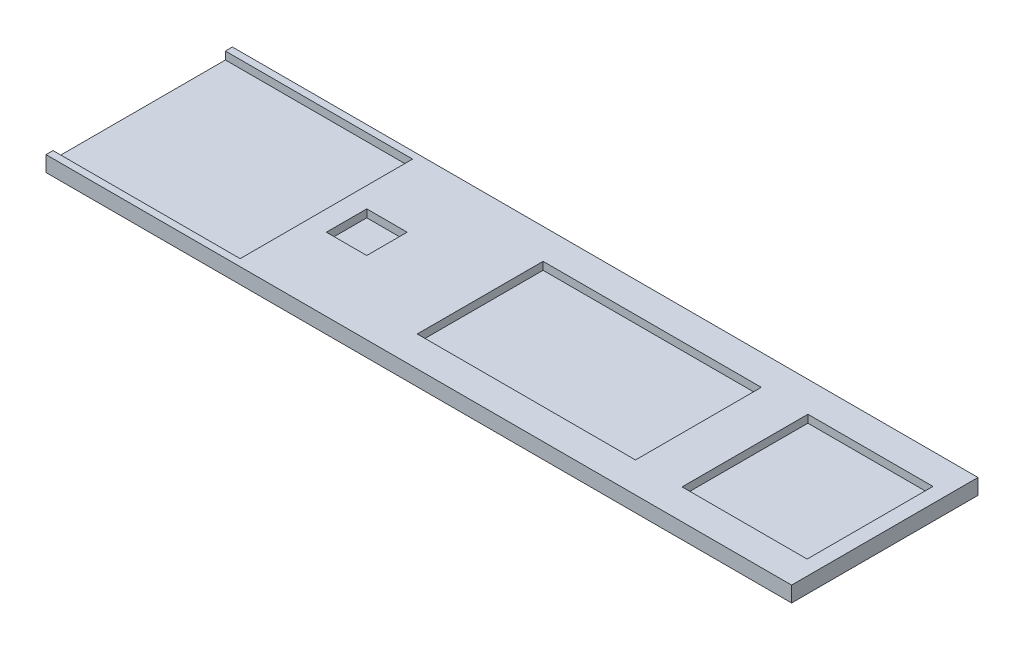
from build123d import *

# Parameters (mm, degrees)
SKETCH1_W           = 240
SKETCH1_H           = 60
BOSS_EXTRUDE1_DEPTH = 5
SKETCH5_W           = 40.25
SKETCH5_H           = 40.5
SKETCH5_W_2         = 70.25
SKETCH5_W_3         = 13
SKETCH5_H_2         = 13
SKETCH5_W_4         = 60.25
SKETCH5_H_3         = 55.5
CUT_EXTRUDE1_DEPTH  = 2.5


with BuildPart() as part:
    # Sketch1 → Boss-Extrude1 (new body)
    with BuildSketch(Plane(origin=(0, 0, 0), x_dir=(1, 0, 0), z_dir=(0, 1, 0))):
        with Locations((115.459074733, 27.68683274)):
            Rectangle(SKETCH1_W, SKETCH1_H)
    extrude(amount=BOSS_EXTRUDE1_DEPTH)

    # Sketch5 → Cut-Extrude1 (cut)
    with BuildSketch(Plane(origin=(0, 5, 0), x_dir=(1, 0, 0), z_dir=(0, 1, 0))):
        with Locations((210.584074733, 27.68683274)):
            Rectangle(SKETCH5_W, SKETCH5_H)
        with Locations((140.334074733, 27.68683274)):
            Rectangle(SKETCH5_W_2, SKETCH5_H)
        with Locations((68.709074733, 27.68683274)):
            Rectangle(SKETCH5_W_3, SKETCH5_H_2)
        with Locations((25.584074733, 27.68683274)):
            Rectangle(SKETCH5_W_4, SKETCH5_H_3)
    extrude(amount=-CUT_EXTRUDE1_DEPTH, mode=Mode.SUBTRACT)


solid = part.part
